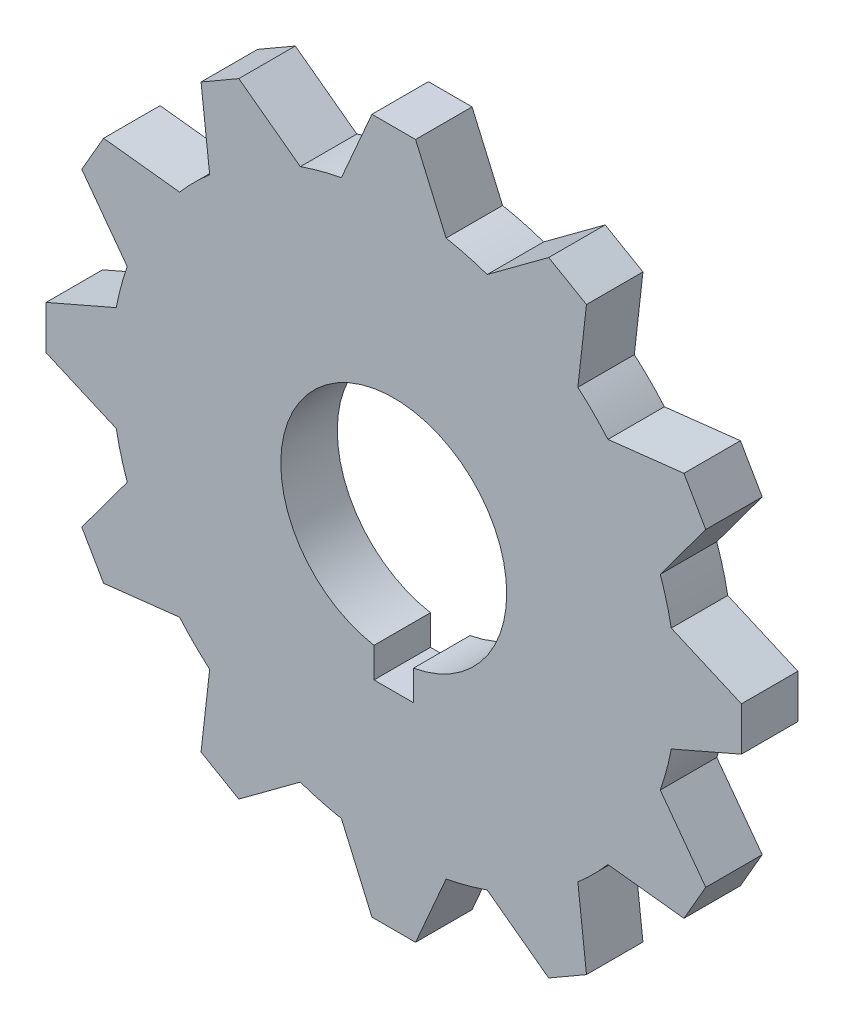
from build123d import *

# Parameters (mm, degrees)
BOSS_EXTRUDE1_DEPTH = 10
CUT_EXTRUDE1_DEPTH  = 10


with BuildPart() as part:
    # Sketch1 → Boss-Extrude1 (new body)
    with BuildSketch(Plane.XY):
        with BuildLine():
            Line((-3.862051717, 61.551449242), (3.862051717, 61.551449242))
            Line((3.862051717, 61.551449242), (9.267481785, 49.133631876))
            ThreePointArc((9.267481785, 49.133631876), (12.940952255, 48.296291314), (16.540941283, 47.184714278))
            Line((16.540941283, 47.184714278), (27.431089723, 55.236144542))
            Line((27.431089723, 55.236144542), (34.120359519, 51.374092825))
            Line((34.120359519, 51.374092825), (32.592690593, 37.917232493))
            ThreePointArc((32.592690593, 37.917232493), (35.355339059, 35.355339059), (37.917232493, 32.592690593))
            Line((37.917232493, 32.592690593), (51.374092825, 34.120359519))
            Line((51.374092825, 34.120359519), (55.236144542, 27.431089723))
            Line((55.236144542, 27.431089723), (47.184714278, 16.540941283))
            ThreePointArc((47.184714278, 16.540941283), (48.296291314, 12.940952255), (49.133631876, 9.267481785))
            Line((49.133631876, 9.267481785), (61.551449242, 3.862051717))
            Line((61.551449242, 3.862051717), (61.551449242, -3.862051717))
            Line((61.551449242, -3.862051717), (49.133631876, -9.267481785))
            ThreePointArc((49.133631876, -9.267481785), (48.296291314, -12.940952255), (47.184714278, -16.540941283))
            Line((47.184714278, -16.540941283), (55.236144542, -27.431089723))
            Line((55.236144542, -27.431089723), (51.374092825, -34.120359519))
            Line((51.374092825, -34.120359519), (37.917232493, -32.592690593))
            ThreePointArc((37.917232493, -32.592690593), (35.355339059, -35.355339059), (32.592690593, -37.917232493))
            Line((32.592690593, -37.917232493), (34.120359519, -51.374092825))
            Line((34.120359519, -51.374092825), (27.431089723, -55.236144542))
            Line((27.431089723, -55.236144542), (16.540941283, -47.184714278))
            ThreePointArc((16.540941283, -47.184714278), (12.940952255, -48.296291314), (9.267481785, -49.133631876))
            Line((9.267481785, -49.133631876), (3.862051717, -61.551449242))
            Line((3.862051717, -61.551449242), (-3.862051717, -61.551449242))
            Line((-3.862051717, -61.551449242), (-9.267481785, -49.133631876))
            ThreePointArc((-9.267481785, -49.133631876), (-12.940952255, -48.296291314), (-16.540941283, -47.184714278))
            Line((-16.540941283, -47.184714278), (-27.431089723, -55.236144542))
            Line((-27.431089723, -55.236144542), (-34.120359519, -51.374092825))
            Line((-34.120359519, -51.374092825), (-32.592690593, -37.917232493))
            ThreePointArc((-32.592690593, -37.917232493), (-35.355339059, -35.355339059), (-37.917232493, -32.592690593))
            Line((-37.917232493, -32.592690593), (-51.374092825, -34.120359519))
            Line((-51.374092825, -34.120359519), (-55.236144542, -27.431089723))
            Line((-55.236144542, -27.431089723), (-47.184714278, -16.540941283))
            ThreePointArc((-47.184714278, -16.540941283), (-48.296291314, -12.940952255), (-49.133631876, -9.267481785))
            Line((-49.133631876, -9.267481785), (-61.551449242, -3.862051717))
            Line((-61.551449242, -3.862051717), (-61.551449242, 3.862051717))
            Line((-61.551449242, 3.862051717), (-49.133631876, 9.267481785))
            ThreePointArc((-49.133631876, 9.267481785), (-48.296291314, 12.940952255), (-47.184714278, 16.540941283))
            Line((-47.184714278, 16.540941283), (-55.236144542, 27.431089723))
            Line((-55.236144542, 27.431089723), (-51.374092825, 34.120359519))
            Line((-51.374092825, 34.120359519), (-37.917232493, 32.592690593))
            ThreePointArc((-37.917232493, 32.592690593), (-35.355339059, 35.355339059), (-32.592690593, 37.917232493))
            Line((-32.592690593, 37.917232493), (-34.120359519, 51.374092825))
            Line((-34.120359519, 51.374092825), (-27.431089723, 55.236144542))
            Line((-27.431089723, 55.236144542), (-16.540941283, 47.184714278))
            ThreePointArc((-16.540941283, 47.184714278), (-12.940952255, 48.296291314), (-9.267481785, 49.133631876))
            Line((-9.267481785, 49.133631876), (-3.862051717, 61.551449242))
        make_face()
    extrude(amount=BOSS_EXTRUDE1_DEPTH)

    # Sketch2 → Cut-Extrude1 (cut)
    with BuildSketch(Plane(origin=(0, 0, 0), x_dir=(-1, 0, 0), z_dir=(0, 0, -1))):
        with BuildLine():
            Line((3.5, -25), (3.5, -19.691368668))
            ThreePointArc((3.5, -19.691368668), (0, 20), (-3.5, -19.691368668))
            Line((-3.5, -19.691368668), (-3.5, -25))
            Line((-3.5, -25), (0, -25))
            Line((0, -25), (3.5, -25))
        make_face()
    extrude(amount=-CUT_EXTRUDE1_DEPTH, mode=Mode.SUBTRACT)


solid = part.part
